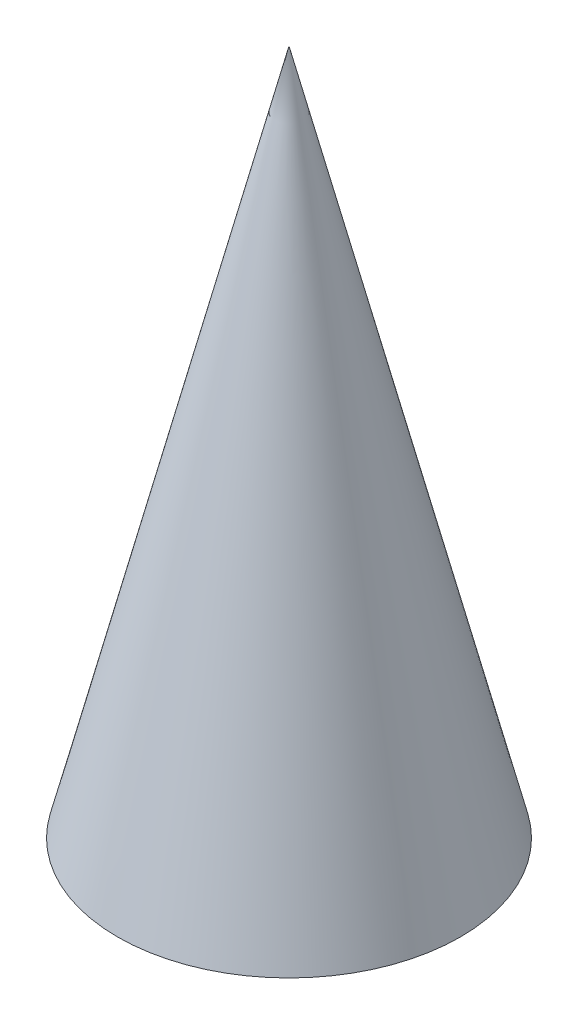
from build123d import *


with BuildPart() as part:
    # Sketch1 → Revolve1 (revolve)
    with BuildSketch(Plane.XY):
        Polygon((0, 0), (10, 0), (0, 40), align=None)
    revolve(axis=Axis((0, 40, 0), (0, -1, 0)))


solid = part.part
